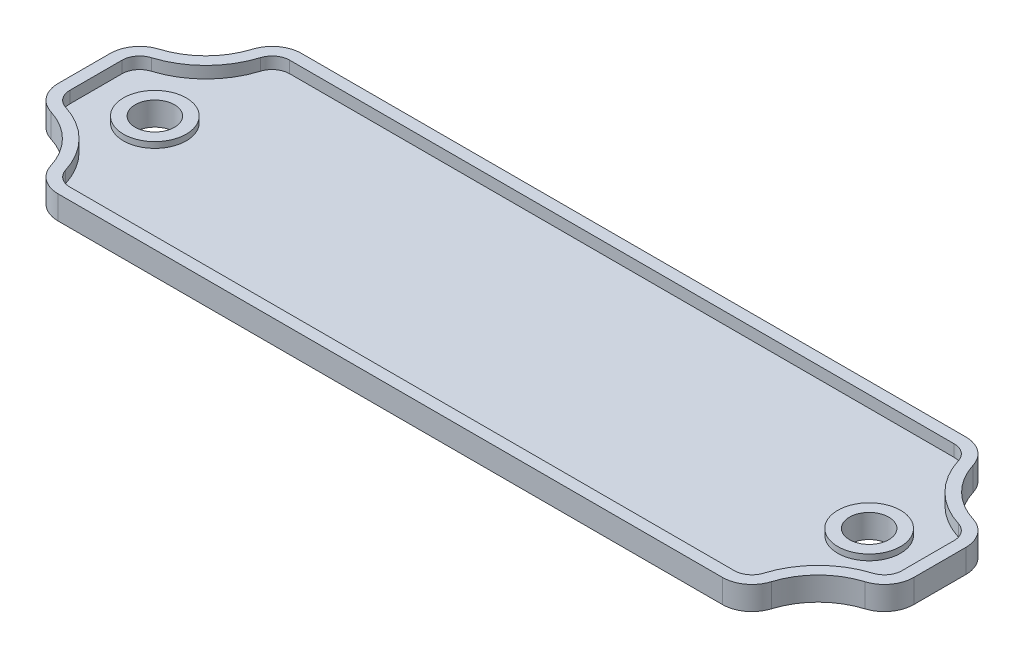
from build123d import *

# Parameters (mm, degrees)
SKETCH1_R           = 4
SKETCH1_R_2         = 2.5
BOSS_EXTRUDE1_DEPTH = 0.75
SKETCH1_3_R         = 4
SKETCH1_3_R_2       = 2.5
BOSS_EXTRUDE2_DEPTH = 1.5
FILLET1_R           = 3.75
BOSS_EXTRUDE3_DEPTH = 1.5


with BuildPart() as part:
    # Sketch1 → Boss-Extrude1 (new body, symmetric)
    with BuildSketch(Plane(origin=(0, 0, 0), x_dir=(1, 0, 0), z_dir=(0, 1, 0))):
        with Locations((-45.5, 0)):
            Circle(SKETCH1_R)
        with Locations((-45.5, 0)):
            Circle(SKETCH1_R_2, mode=Mode.SUBTRACT)
        with BuildLine():
            ThreePointArc((-45.5, -15.5), (-48.136038969, -9.136038969), (-54.5, -6.5))
            Line((-54.5, -6.5), (-54.5, 6.5))
            ThreePointArc((-54.5, 6.5), (-48.136038969, 9.136038969), (-45.5, 15.5))
            Line((-45.5, 15.5), (45.5, 15.5))
            ThreePointArc((45.5, 15.5), (48.136038969, 9.136038969), (54.5, 6.5))
            Line((54.5, 6.5), (54.5, -6.5))
            ThreePointArc((54.5, -6.5), (48.136038969, -9.136038969), (45.5, -15.5))
            Line((45.5, -15.5), (-45.5, -15.5))
        make_face()
        with Locations((-45.5, 0)):
            Circle(SKETCH1_R, mode=Mode.SUBTRACT)
        with Locations((45.5, 0)):
            Circle(SKETCH1_R, mode=Mode.SUBTRACT)
        with Locations((45.5, 0)):
            Circle(SKETCH1_R)
        with Locations((45.5, 0)):
            Circle(SKETCH1_R_2, mode=Mode.SUBTRACT)
    extrude(amount=BOSS_EXTRUDE1_DEPTH, both=True)

    # Sketch1_3 → Boss-Extrude2 (add, symmetric)
    with BuildSketch(Plane(origin=(0, 0, 0), x_dir=(1, 0, 0), z_dir=(0, 1, 0))):
        with Locations((-45.5, 0)):
            Circle(SKETCH1_3_R)
        with Locations((-45.5, 0)):
            Circle(SKETCH1_3_R_2, mode=Mode.SUBTRACT)
        with Locations((45.5, 0)):
            Circle(SKETCH1_3_R)
        with Locations((45.5, 0)):
            Circle(SKETCH1_3_R_2, mode=Mode.SUBTRACT)
    extrude(amount=BOSS_EXTRUDE2_DEPTH, both=True)

    # Fillet1
    fillet1_edges = [part.edges().sort_by_distance(p)[0] for p in [
        (-54.5, 0, 6.5),
        (-54.5, 0, -6.5),
        (-45.5, 0, -15.5),
        (45.5, 0, -15.5),
        (54.5, 0, -6.5),
        (54.5, 0, 6.5),
        (45.5, 0, 15.5),
        (-45.5, 0, 15.5),
    ]]
    fillet(fillet1_edges, radius=FILLET1_R)

    # Sketch2 → Boss-Extrude3 (add)
    with BuildSketch(Plane(origin=(0, 0.75, 0), x_dir=(1, 0, 0), z_dir=(0, 1, 0))):
        with BuildLine():
            Line((-42.313942393, -15.5), (42.313942393, -15.5))
            ThreePointArc((42.313942393, -15.5), (44.541774365, -14.76649875), (45.898076983, -12.852941176))
            ThreePointArc((45.898076983, -12.852941176), (48.136038969, -9.136038969), (51.852941176, -6.898076983))
            ThreePointArc((51.852941176, -6.898076983), (53.76649875, -5.541774365), (54.5, -3.313942393))
            Line((54.5, -3.313942393), (54.5, 3.313942393))
            ThreePointArc((54.5, 3.313942393), (53.76649875, 5.541774365), (51.852941176, 6.898076983))
            ThreePointArc((51.852941176, 6.898076983), (48.136038969, 9.136038969), (45.898076983, 12.852941176))
            ThreePointArc((45.898076983, 12.852941176), (44.541774365, 14.76649875), (42.313942393, 15.5))
            Line((42.313942393, 15.5), (-42.313942393, 15.5))
            ThreePointArc((-42.313942393, 15.5), (-44.541774365, 14.76649875), (-45.898076983, 12.852941176))
            ThreePointArc((-45.898076983, 12.852941176), (-48.136038969, 9.136038969), (-51.852941176, 6.898076983))
            ThreePointArc((-51.852941176, 6.898076983), (-53.76649875, 5.541774365), (-54.5, 3.313942393))
            Line((-54.5, 3.313942393), (-54.5, -3.313942393))
            ThreePointArc((-54.5, -3.313942393), (-53.76649875, -5.541774365), (-51.852941176, -6.898076983))
            ThreePointArc((-51.852941176, -6.898076983), (-48.136038969, -9.136038969), (-45.898076983, -12.852941176))
            ThreePointArc((-45.898076983, -12.852941176), (-44.541774365, -14.76649875), (-42.313942393, -15.5))
        make_face()
        with BuildLine():
            Line((-42.313942393, -14), (42.313942393, -14))
            ThreePointArc((42.313942393, -14), (43.650641576, -13.55989925), (44.464423147, -12.411764706))
            ThreePointArc((44.464423147, -12.411764706), (47.075378798, -8.075378798), (51.411764706, -5.464423147))
            ThreePointArc((51.411764706, -5.464423147), (52.55989925, -4.650641576), (53, -3.313942393))
            Line((53, -3.313942393), (53, 3.313942393))
            ThreePointArc((53, 3.313942393), (52.55989925, 4.650641576), (51.411764706, 5.464423147))
            ThreePointArc((51.411764706, 5.464423147), (47.075378798, 8.075378798), (44.464423147, 12.411764706))
            ThreePointArc((44.464423147, 12.411764706), (43.650641576, 13.55989925), (42.313942393, 14))
            Line((42.313942393, 14), (-42.313942393, 14))
            ThreePointArc((-42.313942393, 14), (-43.650641576, 13.55989925), (-44.464423147, 12.411764706))
            ThreePointArc((-44.464423147, 12.411764706), (-47.075378798, 8.075378798), (-51.411764706, 5.464423147))
            ThreePointArc((-51.411764706, 5.464423147), (-52.55989925, 4.650641576), (-53, 3.313942393))
            Line((-53, 3.313942393), (-53, -3.313942393))
            ThreePointArc((-53, -3.313942393), (-52.55989925, -4.650641576), (-51.411764706, -5.464423147))
            ThreePointArc((-51.411764706, -5.464423147), (-47.075378798, -8.075378798), (-44.464423147, -12.411764706))
            ThreePointArc((-44.464423147, -12.411764706), (-43.650641576, -13.55989925), (-42.313942393, -14))
        make_face(mode=Mode.SUBTRACT)
    extrude(amount=BOSS_EXTRUDE3_DEPTH)


solid = part.part
